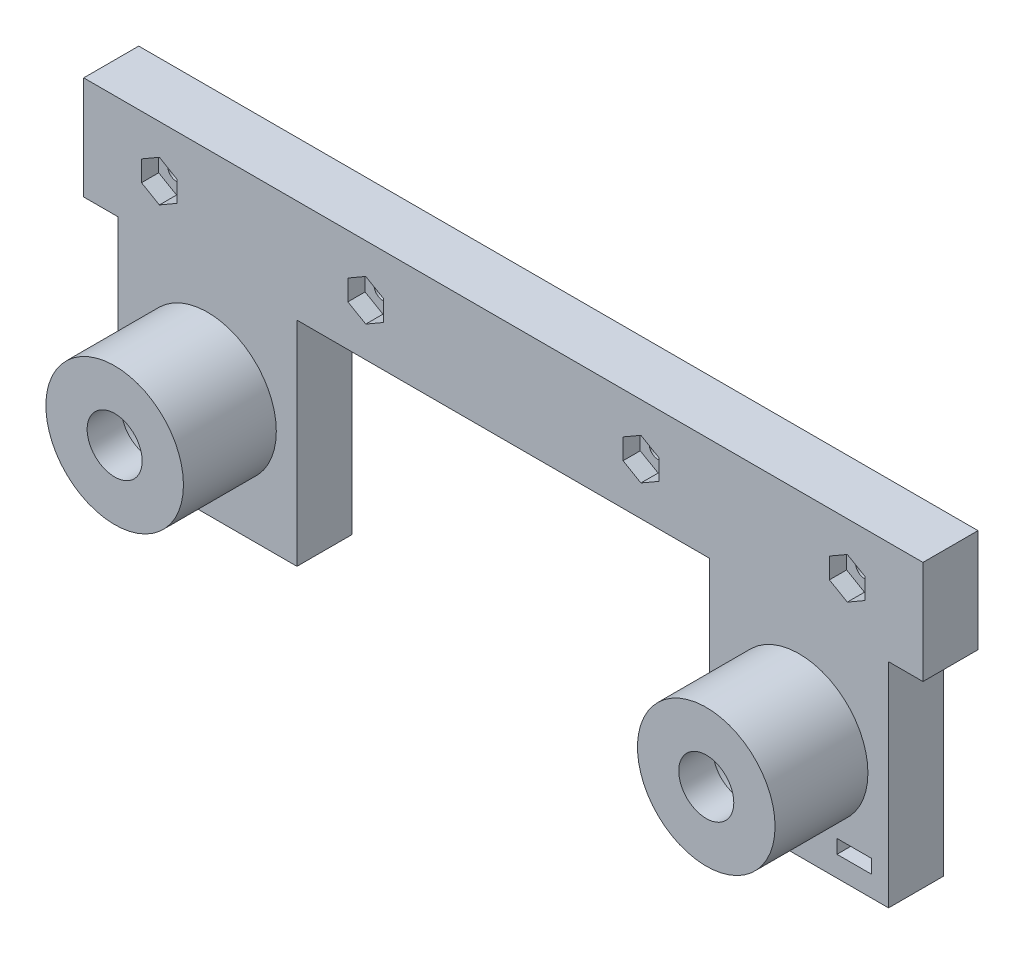
from build123d import *

# Parameters (mm, degrees)
SKETCH1_W               = 122
SKETCH1_H               = 15
BOSS_EXTRUDE1_DEPTH     = 8
SKETCH2_R               = 1.3
CUT_EXTRUDE1_DEPTH      = 1
CUT_EXTRUDE1_DEPTH_BACK = 9
CUT_EXTRUDE3_DEPTH      = 2.5
SKETCH5_W               = 26
SKETCH5_H               = 31
SKETCH5_R               = 7.5
BOSS_EXTRUDE2_DEPTH     = 8
SKETCH6_R               = 10
SKETCH6_R_2             = 7.5
BOSS_EXTRUDE3_DEPTH     = 8.5
SKETCH7_R               = 10
SKETCH7_R_2             = 4
BOSS_EXTRUDE4_DEPTH     = 5
SKETCH8_R               = 1.3
CUT_EXTRUDE4_DEPTH      = 5
SKETCH9_W               = 5
SKETCH9_H               = 2
CUT_EXTRUDE5_DEPTH      = 14.5
CUT_EXTRUDE5_DEPTH_BACK = 9


with BuildPart() as part:
    # Sketch1 → Boss-Extrude1 (new body)
    with BuildSketch(Plane.XY):
        Rectangle(SKETCH1_W, SKETCH1_H)
    extrude(amount=BOSS_EXTRUDE1_DEPTH)

    # Sketch2 → Cut-Extrude1 (cut, two sides)
    with BuildSketch(Plane.XY.offset(8)) as cut_extrude1_sk:
        with Locations((-20, 0)):
            Circle(SKETCH2_R)
        with Locations((20, 0)):
            Circle(SKETCH2_R)
        with Locations((-50, 0)):
            Circle(SKETCH2_R)
        with Locations((50, 0)):
            Circle(SKETCH2_R)
    extrude(amount=CUT_EXTRUDE1_DEPTH, mode=Mode.SUBTRACT)
    extrude(cut_extrude1_sk.sketch, amount=-CUT_EXTRUDE1_DEPTH_BACK, mode=Mode.SUBTRACT)

    # Sketch4 → Cut-Extrude3 (cut)
    with BuildSketch(Plane.XY.offset(8)):
        Polygon((-50, 3), (-52.598076211, 1.5), (-52.598076211, -1.5), (-50, -3), (-47.401923789, -1.5), (-47.401923789, 1.5), align=None)
        Polygon((-20, 3), (-22.598076211, 1.5), (-22.598076211, -1.5), (-20, -3), (-17.401923789, -1.5), (-17.401923789, 1.5), align=None)
        Polygon((20, 3), (17.401923789, 1.5), (17.401923789, -1.5), (20, -3), (22.598076211, -1.5), (22.598076211, 1.5), align=None)
        Polygon((50, 3), (47.401923789, 1.5), (47.401923789, -1.5), (50, -3), (52.598076211, -1.5), (52.598076211, 1.5), align=None)
    extrude(amount=-CUT_EXTRUDE3_DEPTH, mode=Mode.SUBTRACT)

    # Sketch5 → Boss-Extrude2 (add)
    with BuildSketch(Plane.XY):
        with Locations((-43, -23)):
            Rectangle(SKETCH5_W, SKETCH5_H)
        with Locations((-43, -23)):
            Circle(SKETCH5_R, mode=Mode.SUBTRACT)
        with Locations((43, -23)):
            Rectangle(SKETCH5_W, SKETCH5_H)
        with Locations((43, -23)):
            Circle(SKETCH5_R, mode=Mode.SUBTRACT)
    extrude(amount=BOSS_EXTRUDE2_DEPTH)

    # Sketch6 → Boss-Extrude3 (add)
    with BuildSketch(Plane.XY.offset(8)):
        with Locations((-43, -23)):
            Circle(SKETCH6_R)
        with Locations((-43, -23)):
            Circle(SKETCH6_R_2, mode=Mode.SUBTRACT)
        with Locations((43, -23)):
            Circle(SKETCH6_R)
        with Locations((43, -23)):
            Circle(SKETCH6_R_2, mode=Mode.SUBTRACT)
    extrude(amount=BOSS_EXTRUDE3_DEPTH)

    # Sketch7 → Boss-Extrude4 (add)
    with BuildSketch(Plane.XY.offset(16.5)):
        with Locations((-43, -23)):
            Circle(SKETCH7_R)
        with Locations((-43, -23)):
            Circle(SKETCH7_R_2, mode=Mode.SUBTRACT)
        with Locations((43, -23)):
            Circle(SKETCH7_R)
        with Locations((43, -23)):
            Circle(SKETCH7_R_2, mode=Mode.SUBTRACT)
    extrude(amount=BOSS_EXTRUDE4_DEPTH)

    # Sketch8 → Cut-Extrude4 (cut)
    with BuildSketch(Plane.XZ.offset(38.5)):
        with Locations((51, 4)):
            Circle(SKETCH8_R)
        with Locations((-51, 4)):
            Circle(SKETCH8_R)
    extrude(amount=-CUT_EXTRUDE4_DEPTH, mode=Mode.SUBTRACT)

    # Sketch9 → Cut-Extrude5 (cut, two sides)
    with BuildSketch(Plane.XY.offset(8)) as cut_extrude5_sk:
        with Locations((-51, -34.5)):
            Rectangle(SKETCH9_W, SKETCH9_H)
        with Locations((51, -34.5)):
            Rectangle(SKETCH9_W, SKETCH9_H)
    extrude(amount=CUT_EXTRUDE5_DEPTH, mode=Mode.SUBTRACT)
    extrude(cut_extrude5_sk.sketch, amount=-CUT_EXTRUDE5_DEPTH_BACK, mode=Mode.SUBTRACT)


solid = part.part
